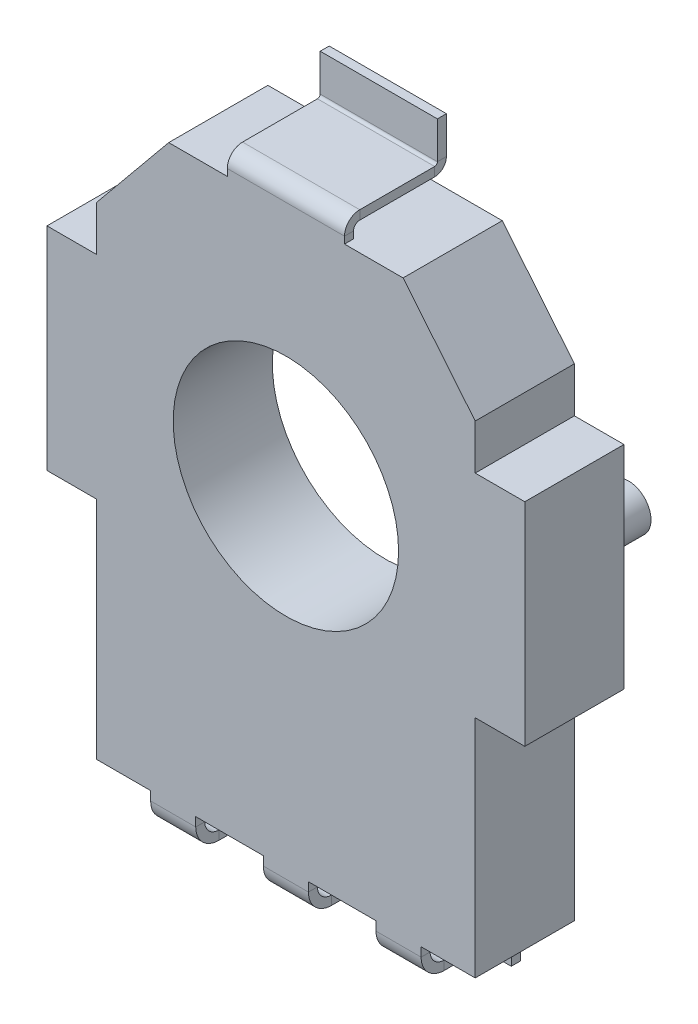
from build123d import *

# Parameters (mm, degrees)
BOSS_EXTRUDE1_DEPTH = 2.2
SKETCH2_W           = 1
SKETCH2_H           = 0.2
SKETCH4_W           = 2.6
SKETCH4_H           = 0.2
SKETCH6_R           = 0.5
BOSS_EXTRUDE2_DEPTH = 1.2


with BuildPart() as part:
    # Sketch1 → Boss-Extrude1 (new body)
    with BuildSketch(Plane.XY):
        with BuildLine():
            Line((0, 5.3), (2.6, 5.3))
            Line((2.6, 5.3), (4.2, 3.35))
            Line((4.2, 3.35), (4.2, 2.35))
            Line((4.2, 2.35), (5.3, 2.35))
            Line((5.3, 2.35), (5.3, -2.35))
            Line((5.3, -2.35), (4.2, -2.35))
            Line((4.2, -2.35), (4.2, -7.35))
            Line((4.2, -7.35), (0, -7.35))
            Line((0, -7.35), (0, -2.5))
            ThreePointArc((0, -2.5), (2.5, 0), (0, 2.5))
            Line((0, 2.5), (0, 5.3))
        make_face()
    boss_extrude1 = extrude(amount=BOSS_EXTRUDE1_DEPTH)

    # Mirror1: Boss-Extrude1 across plane
    add(boss_extrude1.mirror(Plane(origin=(0, -7.35, 2.2), x_dir=(0, 0, 1), z_dir=(1, 0, 0))))

    # Sweep1: sweep along a path in Sketch3
    with BuildLine(Plane(origin=(0, 0, 0), x_dir=(0, 0, -1), z_dir=(1, 0, 0))) as sweep1_path:
        Line((-2, -7.35), (-2, -7.549456001))
        ThreePointArc((-2, -7.549456001), (-1.908338682, -7.770745997), (-1.687048686, -7.862407315))
        Line((-1.687048686, -7.862407315), (-0.312951314, -7.862407315))
        ThreePointArc((-0.312951314, -7.862407315), (-0.091661318, -7.954068633), (0, -8.17535863))
        Line((0, -8.17535863), (0, -8.725))
    # Sketch2 → Sweep1 (sweep)
    with BuildSketch(Plane.XZ.offset(7.35)):
        with Locations((-2.5, 2.1)):
            Rectangle(SKETCH2_W, SKETCH2_H)
        with Locations((0, 2.1)):
            Rectangle(SKETCH2_W, SKETCH2_H)
        with Locations((2.5, 2.1)):
            Rectangle(SKETCH2_W, SKETCH2_H)
    sweep(path=sweep1_path.line)

    # Sweep2: sweep along a path in Sketch5
    with BuildLine(Plane(origin=(0, 0, 0), x_dir=(0, 0, -1), z_dir=(1, 0, 0))) as sweep2_path:
        Line((-2.060981918, 5.3), (-2.060981918, 5.452016603))
        ThreePointArc((-2.060981918, 5.452016603), (-2.002498709, 5.59320756), (-1.861307752, 5.651690769))
        Line((-1.861307752, 5.651690769), (-0.199674166, 5.651690769))
        ThreePointArc((-0.199674166, 5.651690769), (-0.058483209, 5.710173978), (0, 5.851364935))
        Line((0, 5.851364935), (0, 6.675))
    # Sketch4 → Sweep2 (sweep)
    with BuildSketch(Plane(origin=(0, 5.3, 0), x_dir=(1, 0, 0), z_dir=(0, 1, 0))):
        with Locations((0, -2.1)):
            Rectangle(SKETCH4_W, SKETCH4_H)
    sweep(path=sweep2_path.line)

    # Sketch6 → Boss-Extrude2 (add)
    with BuildSketch(Plane(origin=(0, 0, 0), x_dir=(-1, 0, 0), z_dir=(0, 0, -1))):
        with Locations((-4.2, 0)):
            Circle(SKETCH6_R)
        with Locations((4.2, 0)):
            Circle(SKETCH6_R)
    extrude(amount=BOSS_EXTRUDE2_DEPTH)


solid = part.part
